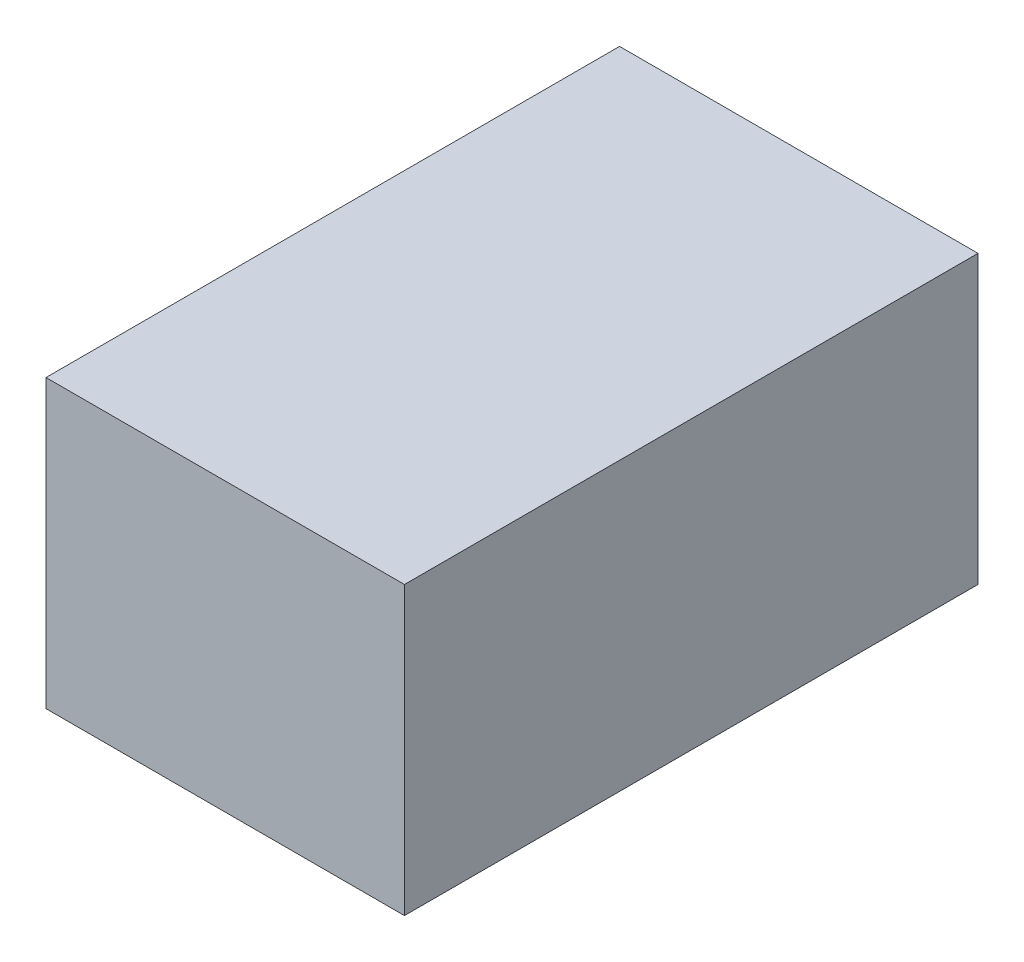
from build123d import *

# Parameters (mm, degrees)
SKETCH1_W  = 31.75
SKETCH1_H  = 25.4
BASE_DEPTH = 50.8


with BuildPart() as part:
    # Sketch1 → base (new body)
    with BuildSketch(Plane.XY):
        with Locations((15.875, 12.7)):
            Rectangle(SKETCH1_W, SKETCH1_H)
    extrude(amount=-BASE_DEPTH)


solid = part.part
